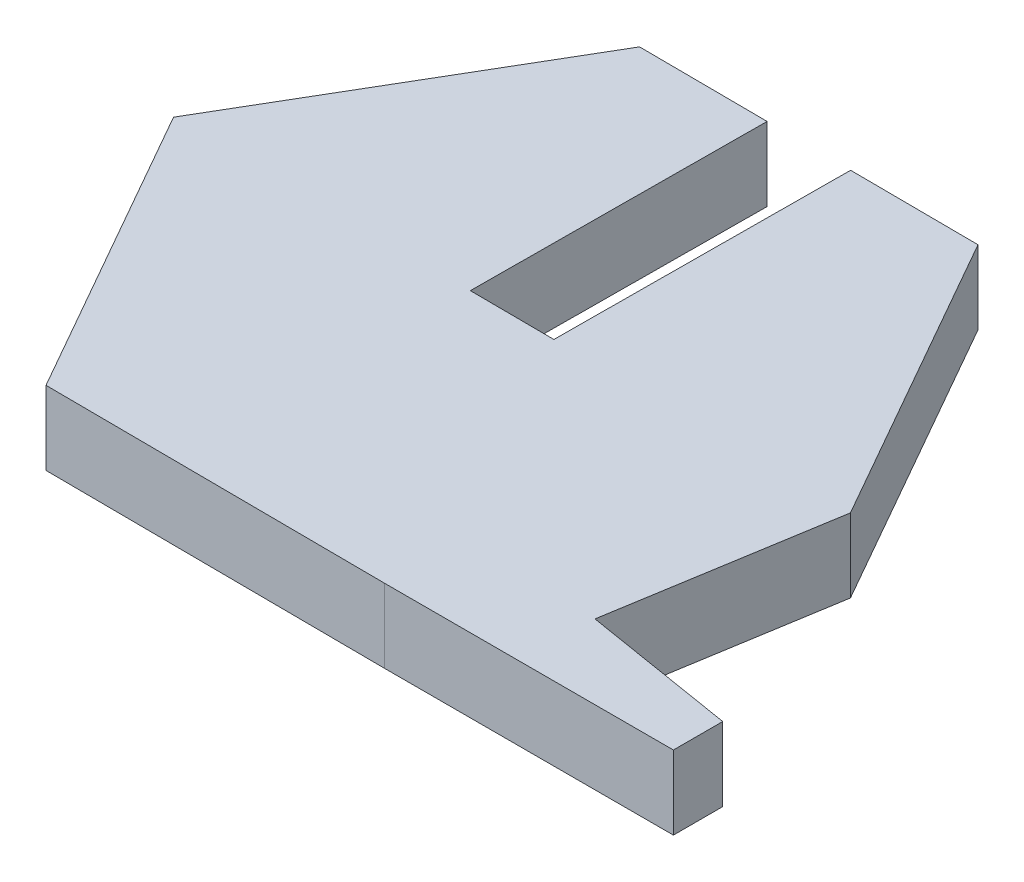
from build123d import *

# Parameters (mm, degrees)
BOSS_EXTRUDE1_DEPTH = 2.5
SKETCH8_W           = 2.85
SKETCH8_H           = 2.5
CUT_EXTRUDE1_DEPTH  = 10


with BuildPart() as part:
    # Sketch1 → Boss-Extrude1 (new body)
    with BuildSketch(Plane(origin=(0, 0, 0), x_dir=(1, 0, 0), z_dir=(0, 1, 0))):
        Polygon((11.546779359, -0.072247979), (10.329867567, -7.516448352), (15.508241902, -8.362963017), (15.508241902, -10.035928246), (5.710821094, -10.035928246), (-5.835958265, -9.963680267), (-11.546779359, 0.072247979), (-5.710821094, 10.035928246), (5.835958265, 9.963680267), align=None)
    extrude(amount=BOSS_EXTRUDE1_DEPTH)

    # Sketch8 → Cut-Extrude1 (cut)
    with BuildSketch(Plane(origin=(0.062568585, 0, -9.999804257), x_dir=(-0.999980426, 0, -0.006256859), z_dir=(0.006256859, 0, -0.999980426))):
        with Locations((-0.002994616, 1.25)):
            Rectangle(SKETCH8_W, SKETCH8_H)
    extrude(amount=-CUT_EXTRUDE1_DEPTH, mode=Mode.SUBTRACT)


solid = part.part
